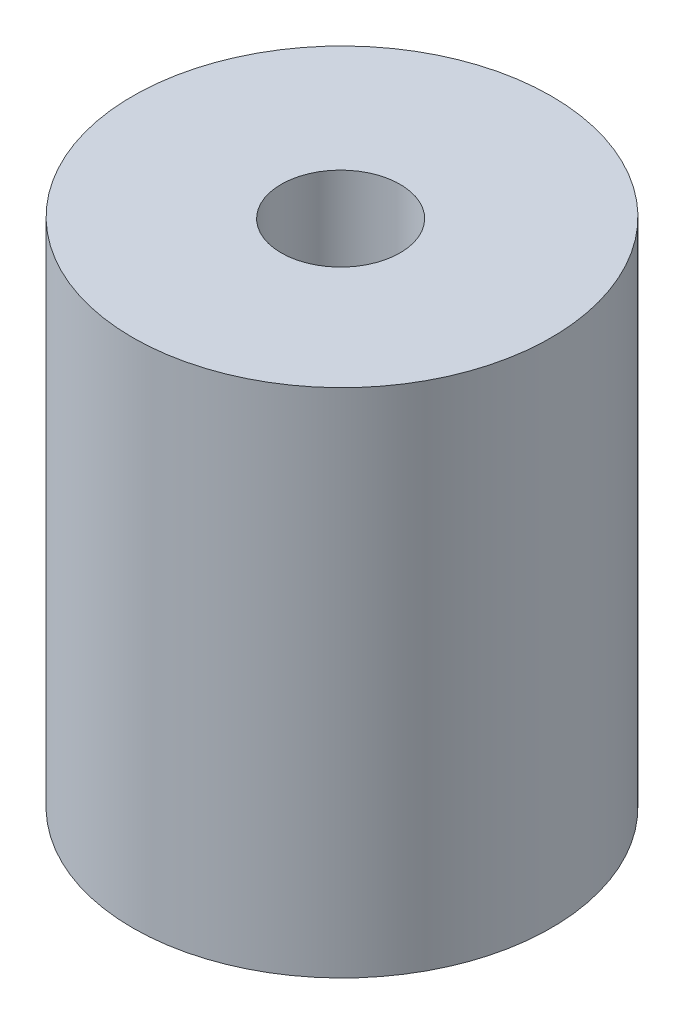
from build123d import *

# Parameters (mm, degrees)
SKETCH1_R           = 22.352
BOSS_EXTRUDE1_DEPTH = 54.61
SKETCH2_R           = 6.35
CUT_EXTRUDE1_DEPTH  = 20.6502
SKETCH3_R           = 6.35
CUT_EXTRUDE2_DEPTH  = 20.6502


with BuildPart() as part:
    # Sketch1 → Boss-Extrude1 (new body)
    with BuildSketch(Plane(origin=(0, 0, 0), x_dir=(1, 0, 0), z_dir=(0, 1, 0))):
        with Locations((-10.585213669, 13.370796213)):
            Circle(SKETCH1_R)
    extrude(amount=BOSS_EXTRUDE1_DEPTH)

    # Sketch2 → Cut-Extrude1 (cut)
    with BuildSketch(Plane(origin=(0, 54.61, 0), x_dir=(1, 0, 0), z_dir=(0, 1, 0))):
        with Locations((-10.493492602, 13.133399692)):
            Circle(SKETCH2_R)
    extrude(amount=-CUT_EXTRUDE1_DEPTH, mode=Mode.SUBTRACT)

    # Sketch3 → Cut-Extrude2 (cut)
    with BuildSketch(Plane(origin=(0, 0, 0), x_dir=(-1, 0, 0), z_dir=(0, -1, 0))):
        with Locations((10.493492678, 13.133399692)):
            Circle(SKETCH3_R)
    extrude(amount=-CUT_EXTRUDE2_DEPTH, mode=Mode.SUBTRACT)


solid = part.part
